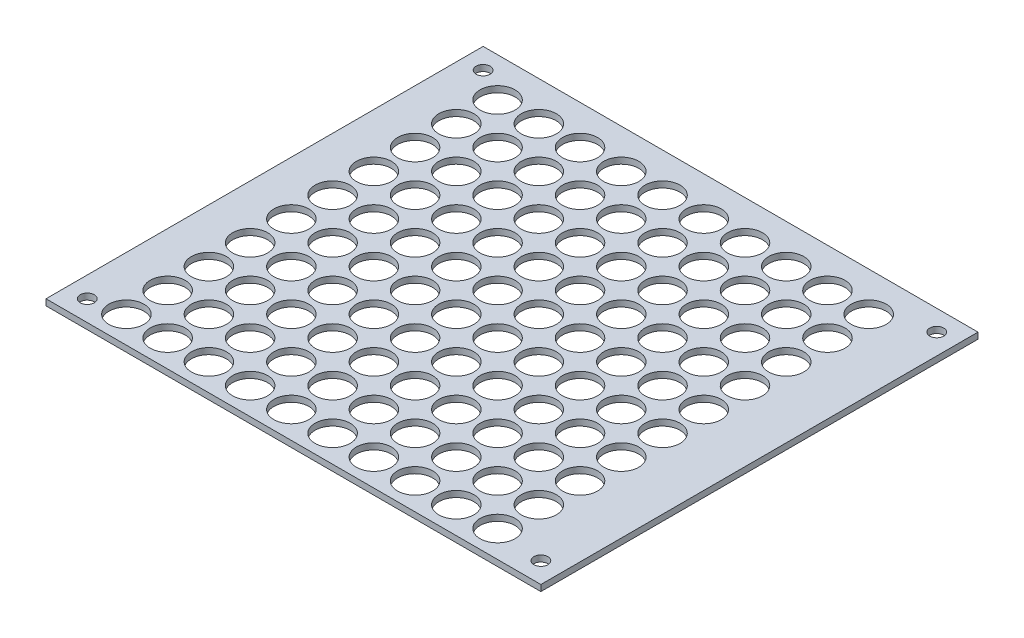
from build123d import *

# Parameters (mm, degrees)
SKETCH1_W           = 120
SKETCH1_H           = 106
SKETCH1_R           = 4.25
SKETCH1_R_2         = 1.7
BOSS_EXTRUDE1_DEPTH = 1.5


with BuildPart() as part:
    # Sketch1 → Boss-Extrude1 (new body)
    with BuildSketch(Plane(origin=(0, 0, 0), x_dir=(1, 0, 0), z_dir=(0, 1, 0))):
        with Locations((60, 53)):
            Rectangle(SKETCH1_W, SKETCH1_H)
        with Locations((13, 36.5)):
            Circle(SKETCH1_R, mode=Mode.SUBTRACT)
        with Locations((23, 36.5)):
            Circle(SKETCH1_R, mode=Mode.SUBTRACT)
        with Locations((13, 6.5)):
            Circle(SKETCH1_R, mode=Mode.SUBTRACT)
        with Locations((5, 5)):
            Circle(SKETCH1_R_2, mode=Mode.SUBTRACT)
        with Locations((5, 101)):
            Circle(SKETCH1_R_2, mode=Mode.SUBTRACT)
        with Locations((115, 101)):
            Circle(SKETCH1_R_2, mode=Mode.SUBTRACT)
        with Locations((115, 5)):
            Circle(SKETCH1_R_2, mode=Mode.SUBTRACT)
        with Locations((23, 6.5)):
            Circle(SKETCH1_R, mode=Mode.SUBTRACT)
        with Locations((33, 6.5)):
            Circle(SKETCH1_R, mode=Mode.SUBTRACT)
        with Locations((23, 16.5)):
            Circle(SKETCH1_R, mode=Mode.SUBTRACT)
        with Locations((33, 16.5)):
            Circle(SKETCH1_R, mode=Mode.SUBTRACT)
        with Locations((23, 26.5)):
            Circle(SKETCH1_R, mode=Mode.SUBTRACT)
        with Locations((33, 26.5)):
            Circle(SKETCH1_R, mode=Mode.SUBTRACT)
        with Locations((13, 16.5)):
            Circle(SKETCH1_R, mode=Mode.SUBTRACT)
        with Locations((13, 26.5)):
            Circle(SKETCH1_R, mode=Mode.SUBTRACT)
        with Locations((33, 36.5)):
            Circle(SKETCH1_R, mode=Mode.SUBTRACT)
        with Locations((13, 46.5)):
            Circle(SKETCH1_R, mode=Mode.SUBTRACT)
        with Locations((23, 46.5)):
            Circle(SKETCH1_R, mode=Mode.SUBTRACT)
        with Locations((33, 46.5)):
            Circle(SKETCH1_R, mode=Mode.SUBTRACT)
        with Locations((13, 56.5)):
            Circle(SKETCH1_R, mode=Mode.SUBTRACT)
        with Locations((23, 56.5)):
            Circle(SKETCH1_R, mode=Mode.SUBTRACT)
        with Locations((33, 56.5)):
            Circle(SKETCH1_R, mode=Mode.SUBTRACT)
        with Locations((13, 66.5)):
            Circle(SKETCH1_R, mode=Mode.SUBTRACT)
        with Locations((23, 66.5)):
            Circle(SKETCH1_R, mode=Mode.SUBTRACT)
        with Locations((33, 66.5)):
            Circle(SKETCH1_R, mode=Mode.SUBTRACT)
        with Locations((13, 76.5)):
            Circle(SKETCH1_R, mode=Mode.SUBTRACT)
        with Locations((23, 76.5)):
            Circle(SKETCH1_R, mode=Mode.SUBTRACT)
        with Locations((33, 76.5)):
            Circle(SKETCH1_R, mode=Mode.SUBTRACT)
        with Locations((13, 86.5)):
            Circle(SKETCH1_R, mode=Mode.SUBTRACT)
        with Locations((23, 86.5)):
            Circle(SKETCH1_R, mode=Mode.SUBTRACT)
        with Locations((33, 86.5)):
            Circle(SKETCH1_R, mode=Mode.SUBTRACT)
        with Locations((13, 96.5)):
            Circle(SKETCH1_R, mode=Mode.SUBTRACT)
        with Locations((23, 96.5)):
            Circle(SKETCH1_R, mode=Mode.SUBTRACT)
        with Locations((33, 96.5)):
            Circle(SKETCH1_R, mode=Mode.SUBTRACT)
        with Locations((43, 6.5)):
            Circle(SKETCH1_R, mode=Mode.SUBTRACT)
        with Locations((53, 6.5)):
            Circle(SKETCH1_R, mode=Mode.SUBTRACT)
        with Locations((63, 6.5)):
            Circle(SKETCH1_R, mode=Mode.SUBTRACT)
        with Locations((73, 6.5)):
            Circle(SKETCH1_R, mode=Mode.SUBTRACT)
        with Locations((83, 6.5)):
            Circle(SKETCH1_R, mode=Mode.SUBTRACT)
        with Locations((93, 6.5)):
            Circle(SKETCH1_R, mode=Mode.SUBTRACT)
        with Locations((103, 6.5)):
            Circle(SKETCH1_R, mode=Mode.SUBTRACT)
        with Locations((43, 16.5)):
            Circle(SKETCH1_R, mode=Mode.SUBTRACT)
        with Locations((53, 16.5)):
            Circle(SKETCH1_R, mode=Mode.SUBTRACT)
        with Locations((63, 16.5)):
            Circle(SKETCH1_R, mode=Mode.SUBTRACT)
        with Locations((73, 16.5)):
            Circle(SKETCH1_R, mode=Mode.SUBTRACT)
        with Locations((83, 16.5)):
            Circle(SKETCH1_R, mode=Mode.SUBTRACT)
        with Locations((93, 16.5)):
            Circle(SKETCH1_R, mode=Mode.SUBTRACT)
        with Locations((103, 16.5)):
            Circle(SKETCH1_R, mode=Mode.SUBTRACT)
        with Locations((43, 26.5)):
            Circle(SKETCH1_R, mode=Mode.SUBTRACT)
        with Locations((53, 26.5)):
            Circle(SKETCH1_R, mode=Mode.SUBTRACT)
        with Locations((63, 26.5)):
            Circle(SKETCH1_R, mode=Mode.SUBTRACT)
        with Locations((73, 26.5)):
            Circle(SKETCH1_R, mode=Mode.SUBTRACT)
        with Locations((83, 26.5)):
            Circle(SKETCH1_R, mode=Mode.SUBTRACT)
        with Locations((93, 26.5)):
            Circle(SKETCH1_R, mode=Mode.SUBTRACT)
        with Locations((103, 26.5)):
            Circle(SKETCH1_R, mode=Mode.SUBTRACT)
        with Locations((43, 36.5)):
            Circle(SKETCH1_R, mode=Mode.SUBTRACT)
        with Locations((53, 36.5)):
            Circle(SKETCH1_R, mode=Mode.SUBTRACT)
        with Locations((63, 36.5)):
            Circle(SKETCH1_R, mode=Mode.SUBTRACT)
        with Locations((73, 36.5)):
            Circle(SKETCH1_R, mode=Mode.SUBTRACT)
        with Locations((83, 36.5)):
            Circle(SKETCH1_R, mode=Mode.SUBTRACT)
        with Locations((93, 36.5)):
            Circle(SKETCH1_R, mode=Mode.SUBTRACT)
        with Locations((103, 36.5)):
            Circle(SKETCH1_R, mode=Mode.SUBTRACT)
        with Locations((43, 46.5)):
            Circle(SKETCH1_R, mode=Mode.SUBTRACT)
        with Locations((53, 46.5)):
            Circle(SKETCH1_R, mode=Mode.SUBTRACT)
        with Locations((63, 46.5)):
            Circle(SKETCH1_R, mode=Mode.SUBTRACT)
        with Locations((73, 46.5)):
            Circle(SKETCH1_R, mode=Mode.SUBTRACT)
        with Locations((83, 46.5)):
            Circle(SKETCH1_R, mode=Mode.SUBTRACT)
        with Locations((93, 46.5)):
            Circle(SKETCH1_R, mode=Mode.SUBTRACT)
        with Locations((103, 46.5)):
            Circle(SKETCH1_R, mode=Mode.SUBTRACT)
        with Locations((43, 56.5)):
            Circle(SKETCH1_R, mode=Mode.SUBTRACT)
        with Locations((53, 56.5)):
            Circle(SKETCH1_R, mode=Mode.SUBTRACT)
        with Locations((63, 56.5)):
            Circle(SKETCH1_R, mode=Mode.SUBTRACT)
        with Locations((73, 56.5)):
            Circle(SKETCH1_R, mode=Mode.SUBTRACT)
        with Locations((83, 56.5)):
            Circle(SKETCH1_R, mode=Mode.SUBTRACT)
        with Locations((93, 56.5)):
            Circle(SKETCH1_R, mode=Mode.SUBTRACT)
        with Locations((103, 56.5)):
            Circle(SKETCH1_R, mode=Mode.SUBTRACT)
        with Locations((43, 66.5)):
            Circle(SKETCH1_R, mode=Mode.SUBTRACT)
        with Locations((53, 66.5)):
            Circle(SKETCH1_R, mode=Mode.SUBTRACT)
        with Locations((63, 66.5)):
            Circle(SKETCH1_R, mode=Mode.SUBTRACT)
        with Locations((73, 66.5)):
            Circle(SKETCH1_R, mode=Mode.SUBTRACT)
        with Locations((83, 66.5)):
            Circle(SKETCH1_R, mode=Mode.SUBTRACT)
        with Locations((93, 66.5)):
            Circle(SKETCH1_R, mode=Mode.SUBTRACT)
        with Locations((103, 66.5)):
            Circle(SKETCH1_R, mode=Mode.SUBTRACT)
        with Locations((43, 76.5)):
            Circle(SKETCH1_R, mode=Mode.SUBTRACT)
        with Locations((53, 76.5)):
            Circle(SKETCH1_R, mode=Mode.SUBTRACT)
        with Locations((63, 76.5)):
            Circle(SKETCH1_R, mode=Mode.SUBTRACT)
        with Locations((73, 76.5)):
            Circle(SKETCH1_R, mode=Mode.SUBTRACT)
        with Locations((83, 76.5)):
            Circle(SKETCH1_R, mode=Mode.SUBTRACT)
        with Locations((93, 76.5)):
            Circle(SKETCH1_R, mode=Mode.SUBTRACT)
        with Locations((103, 76.5)):
            Circle(SKETCH1_R, mode=Mode.SUBTRACT)
        with Locations((43, 86.5)):
            Circle(SKETCH1_R, mode=Mode.SUBTRACT)
        with Locations((53, 86.5)):
            Circle(SKETCH1_R, mode=Mode.SUBTRACT)
        with Locations((63, 86.5)):
            Circle(SKETCH1_R, mode=Mode.SUBTRACT)
        with Locations((73, 86.5)):
            Circle(SKETCH1_R, mode=Mode.SUBTRACT)
        with Locations((83, 86.5)):
            Circle(SKETCH1_R, mode=Mode.SUBTRACT)
        with Locations((93, 86.5)):
            Circle(SKETCH1_R, mode=Mode.SUBTRACT)
        with Locations((103, 86.5)):
            Circle(SKETCH1_R, mode=Mode.SUBTRACT)
        with Locations((43, 96.5)):
            Circle(SKETCH1_R, mode=Mode.SUBTRACT)
        with Locations((53, 96.5)):
            Circle(SKETCH1_R, mode=Mode.SUBTRACT)
        with Locations((63, 96.5)):
            Circle(SKETCH1_R, mode=Mode.SUBTRACT)
        with Locations((73, 96.5)):
            Circle(SKETCH1_R, mode=Mode.SUBTRACT)
        with Locations((83, 96.5)):
            Circle(SKETCH1_R, mode=Mode.SUBTRACT)
        with Locations((93, 96.5)):
            Circle(SKETCH1_R, mode=Mode.SUBTRACT)
        with Locations((103, 96.5)):
            Circle(SKETCH1_R, mode=Mode.SUBTRACT)
    extrude(amount=BOSS_EXTRUDE1_DEPTH)


solid = part.part
